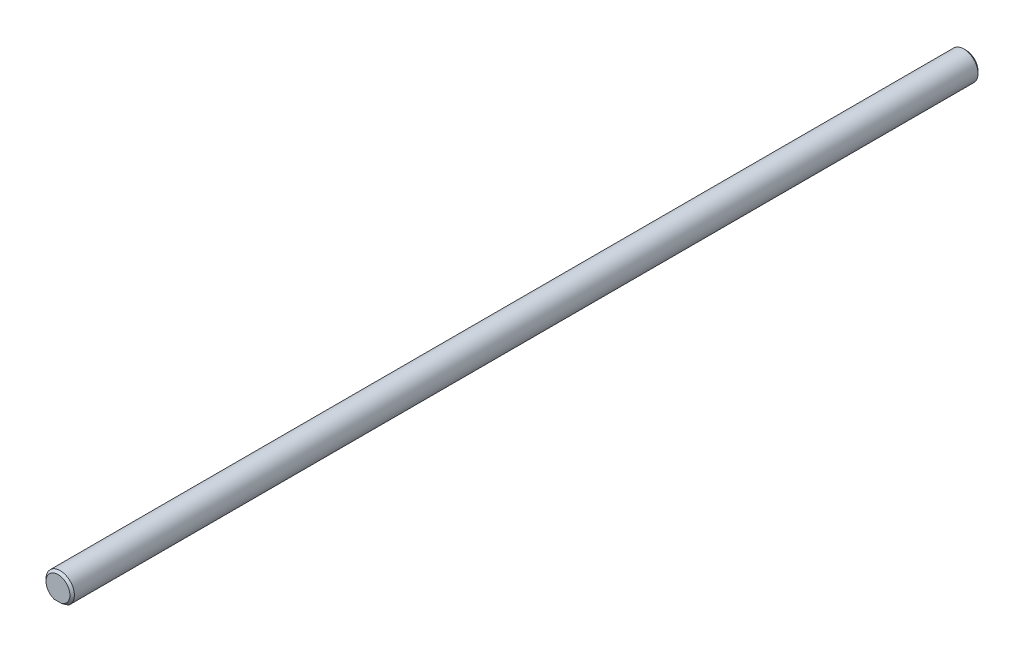
from build123d import *

# Parameters (mm, degrees)
CHAMFER1_SIZE = 0.5


with BuildPart() as part:
    # Sweep1: sweep along a path in Sketch2
    with BuildLine(Plane(origin=(0, 0, 0), x_dir=(1, 0, 0), z_dir=(0, 1, 0))) as sweep1_path:
        Line((0, -101.6), (0, 101.6))
    # Sketch1 → Sweep1 (sweep)
    with BuildSketch(Plane.XY):
        with BuildLine():
            Line((-1.905, -2.54), (1.905, -2.54))
            ThreePointArc((1.905, -2.54), (0, 3.175), (-1.905, -2.54))
        make_face()
    sweep(path=sweep1_path.line)

    # Chamfer1
    chamfer1_edges = [part.edges().sort_by_distance(p)[0] for p in [
        (0, 3.175, -101.6),
        (0, 3.175, 101.6),
    ]]
    chamfer(chamfer1_edges, length=CHAMFER1_SIZE)


solid = part.part
